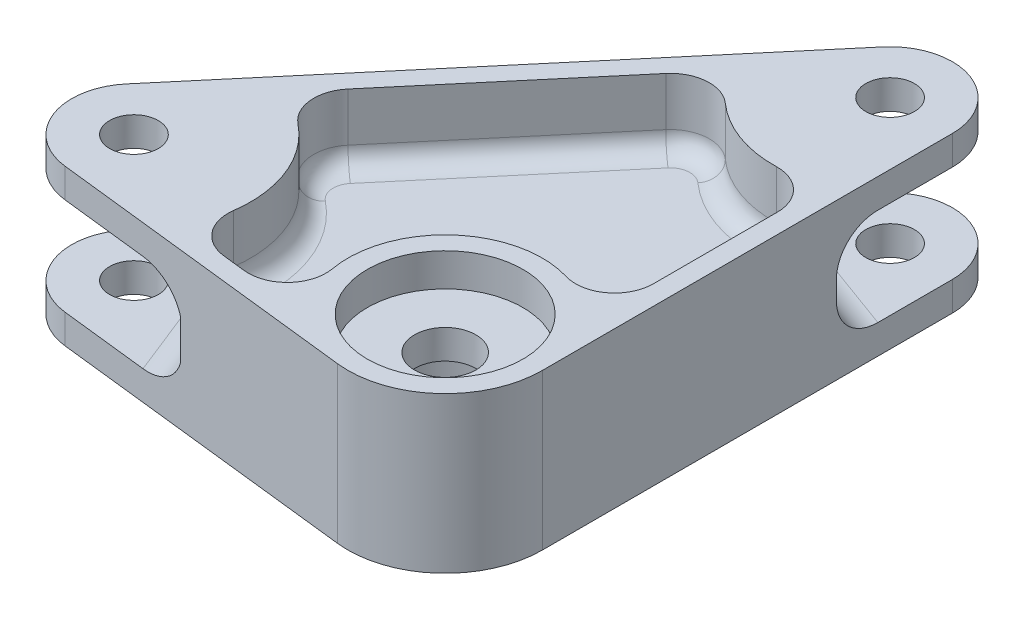
from build123d import *

# Parameters (mm, degrees)
BOSS_EXTRUDE2_DEPTH = 12.7
SKETCH3_R           = 12
CUT_EXTRUDE1_DEPTH  = 15.24
SKETCH5_R           = 3.96875
CUT_EXTRUDE3_DEPTH  = 26.4
SKETCH4_R           = 5
CUT_EXTRUDE2_DEPTH  = 26.4
CUT_EXTRUDE4_DEPTH  = 11.1125
CUT_EXTRUDE5_DEPTH  = 11.1125
SKETCH10_R          = 12.7
CUT_EXTRUDE6_DEPTH  = 5.3975
CUT_EXTRUDE7_REACH  = 29.328
SKETCH12_W          = 38.1
SKETCH12_H          = 15.875
CUT_EXTRUDE8_REACH  = 31.596
SKETCH15_W          = 38.1
SKETCH15_H          = 15.875
FILLET1_R           = 3.175
FILLET2_R           = 3.175
FILLET3_R           = 6.35
CHAMFER1_SIZE       = 0.635


with BuildPart() as part:
    # Sketch2 → Boss-Extrude2 (new body, symmetric)
    with BuildSketch(Plane(origin=(0, 0, 0), x_dir=(1, 0, 0), z_dir=(0, 1, 0))):
        with BuildLine():
            Line((-58.565346794, 6.551716506), (-2.085197783, 73.494164894))
            ThreePointArc((-2.085197783, 73.494164894), (9.165477674, 76.485932244), (15.840147634, 66.947737915))
            Line((15.840147634, 66.947737915), (15.874997849, 0.008264886))
            ThreePointArc((15.874997849, 0.008264886), (10.578143579, -11.83716619), (-1.7859375, -15.77422113))
            Line((-1.7859375, -15.77422113), (-51.943, -10.095501523))
            ThreePointArc((-51.943, -10.095501523), (-60.240451667, -3.755459003), (-58.565346794, 6.551716506))
        make_face()
    extrude(amount=BOSS_EXTRUDE2_DEPTH, both=True)

    # Sketch3 → Cut-Extrude1 (cut)
    with BuildSketch(Plane.XZ.offset(12.7)):
        Circle(SKETCH3_R)
    extrude(amount=-CUT_EXTRUDE1_DEPTH, mode=Mode.SUBTRACT)

    # Sketch5 → Cut-Extrude3 (cut, through all)
    with BuildSketch(Plane(origin=(0, 12.7, 0), x_dir=(1, 0, 0), z_dir=(0, 1, 0))):
        with Locations((-50.8, 0)):
            Circle(SKETCH5_R)
        with Locations((5.680149011, 66.942448388)):
            Circle(SKETCH5_R)
    extrude(amount=-CUT_EXTRUDE3_DEPTH, mode=Mode.SUBTRACT)

    # Sketch4 → Cut-Extrude2 (cut, through all)
    with BuildSketch(Plane(origin=(0, 12.7, 0), x_dir=(1, 0, 0), z_dir=(0, 1, 0))):
        Circle(SKETCH4_R)
    extrude(amount=-CUT_EXTRUDE2_DEPTH, mode=Mode.SUBTRACT)

    # Sketch6 → Cut-Extrude4 (cut)
    with BuildSketch(Plane(origin=(0, 12.7, 0), x_dir=(1, 0, 0), z_dir=(0, 1, 0))):
        with BuildLine():
            Line((-39.764503985, 23.911604457), (-16.032698846, 52.039454127))
            ThreePointArc((-16.032698846, 52.039454127), (-11.636571539, 54.278149682), (-6.964480572, 52.69408558))
            ThreePointArc((-6.964480572, 52.69408558), (-0.854842234, 49.048416159), (6.166313709, 47.898652971))
            ThreePointArc((6.166313709, 47.898652971), (10.759647518, 46.098936994), (12.678367748, 41.55402712))
            Line((12.678367748, 41.55402712), (12.688909771, 21.305156508))
            ThreePointArc((12.688909771, 21.305156508), (10.136411612, 16.212500271), (4.527793308, 15.215607538))
            ThreePointArc((4.527793308, 15.215607538), (-10.578143579, 11.83716619), (-15.626938173, -2.7954299))
            ThreePointArc((-15.626938173, -2.7954299), (-17.245628646, -8.257136186), (-22.592088443, -10.223290312))
            Line((-22.592088443, -10.223290312), (-26.354947036, -9.797264189))
            ThreePointArc((-26.354947036, -9.797264189), (-30.656406746, -7.381661273), (-31.930429027, -2.615681803))
            ThreePointArc((-31.930429027, -2.615681803), (-33.099153125, 7.041485631), (-38.883371679, 14.862586231))
            ThreePointArc((-38.883371679, 14.862586231), (-41.231270715, 19.201372144), (-39.764503985, 23.911604457))
        make_face()
    extrude(amount=-CUT_EXTRUDE4_DEPTH, mode=Mode.SUBTRACT)

    # Sketch8 → Cut-Extrude5 (cut)
    with BuildSketch(Plane.XZ.offset(12.7)):
        with BuildLine():
            Line((-26.354947036, 9.797264189), (-22.592088443, 10.223290312))
            ThreePointArc((-22.592088443, 10.223290312), (-17.245628646, 8.257136186), (-15.626938173, 2.7954299))
            ThreePointArc((-15.626938173, 2.7954299), (-10.578143579, -11.83716619), (4.527793308, -15.215607538))
            ThreePointArc((4.527793308, -15.215607538), (10.136411612, -16.212500271), (12.688909771, -21.305156508))
            Line((12.688909771, -21.305156508), (12.678367748, -41.55402712))
            ThreePointArc((12.678367748, -41.55402712), (10.759647518, -46.098936994), (6.166313709, -47.898652971))
            ThreePointArc((6.166313709, -47.898652971), (-0.854842234, -49.048416159), (-6.964480572, -52.69408558))
            ThreePointArc((-6.964480572, -52.69408558), (-11.636571539, -54.278149682), (-16.032698846, -52.039454127))
            Line((-16.032698846, -52.039454127), (-39.764503985, -23.911604457))
            ThreePointArc((-39.764503985, -23.911604457), (-41.231270715, -19.201372144), (-38.883371679, -14.862586231))
            ThreePointArc((-38.883371679, -14.862586231), (-33.099153125, -7.041485631), (-31.930429027, 2.615681803))
            ThreePointArc((-31.930429027, 2.615681803), (-30.656406746, 7.381661273), (-26.354947036, 9.797264189))
        make_face()
    extrude(amount=-CUT_EXTRUDE5_DEPTH, mode=Mode.SUBTRACT)

    # Sketch10 → Cut-Extrude6 (cut)
    with BuildSketch(Plane(origin=(0, 12.7, 0), x_dir=(1, 0, 0), z_dir=(0, 1, 0))):
        Circle(SKETCH10_R)
    extrude(amount=-CUT_EXTRUDE6_DEPTH, mode=Mode.SUBTRACT)

    # Sketch12 → Cut-Extrude7 (cut, up to next)
    with BuildSketch(Plane(origin=(17.337923239, 0, -47.474487057), x_dir=(0.939319277, 0, 0.34304416), z_dir=(-0.34304416, 0, 0.939319277)), mode=Mode.PRIVATE) as cut_extrude7_sk1:
        with Locations((-17.6287425, 0)):
            Rectangle(SKETCH12_W, SKETCH12_H)
    cut_extrude7_tool1 = extrude(cut_extrude7_sk1.sketch, amount=-CUT_EXTRUDE7_REACH, mode=Mode.PRIVATE) & part.part
    add(cut_extrude7_tool1.solids().sort_by_distance((0.778906, 0, -53.521924))[0], mode=Mode.SUBTRACT)

    # Sketch15 → Cut-Extrude8 (cut, up to next)
    with BuildSketch(Plane(origin=(-30.583679643, 0, 12.166341096), x_dir=(0.369631792, 0, 0.929178314), z_dir=(-0.929178314, 0, 0.369631792)), mode=Mode.PRIVATE) as cut_extrude8_sk1:
        with Locations((-18.777295017, 0)):
            Rectangle(SKETCH15_W, SKETCH15_H)
    cut_extrude8_tool1 = extrude(cut_extrude8_sk1.sketch, amount=CUT_EXTRUDE8_REACH, mode=Mode.PRIVATE) & part.part
    add(cut_extrude8_tool1.solids().sort_by_distance((-37.524365, 0, -5.281114))[0], mode=Mode.SUBTRACT)

    # Fillet1
    fillet1_edges = [part.edges().sort_by_distance(p)[0] for p in [
        (-30.656406746, 1.5875, 7.381661273),
        (-33.099153125, 1.5875, -7.041485631),
        (-41.231270715, 1.5875, -19.201372144),
        (-27.898601415, 1.5875, -37.975529292),
        (-11.636571539, 1.5875, -54.278149682),
        (-0.854842234, 1.5875, -49.048416159),
        (10.759647518, 1.5875, -46.098936994),
        (12.68363876, 1.5875, -31.429591814),
        (10.136411612, 1.5875, -16.212500271),
        (-10.578143579, 1.5875, -11.83716619),
        (-17.245628646, 1.5875, 8.257136186),
        (-24.473517739, 1.5875, 10.01027725),
    ]]
    fillet(fillet1_edges, radius=FILLET1_R)

    # Fillet2
    fillet2_edges = [part.edges().sort_by_distance(p)[0] for p in [
        (-17.245628646, -1.5875, 8.257136186),
        (-10.578143579, -1.5875, -11.83716619),
        (10.136411612, -1.5875, -16.212500271),
        (12.68363876, -1.5875, -31.429591814),
        (10.759647518, -1.5875, -46.098936994),
        (-0.854842234, -1.5875, -49.048416159),
        (-11.636571539, -1.5875, -54.278149682),
        (-27.898601415, -1.5875, -37.975529292),
        (-41.231270715, -1.5875, -19.201372144),
        (-33.099153125, -1.5875, -7.041485631),
        (-30.656406746, -1.5875, 7.381661273),
        (-24.473517739, -1.5875, 10.01027725),
    ]]
    fillet(fillet2_edges, radius=FILLET2_R)

    # Fillet3
    fillet3_edges = [part.edges().sort_by_distance(p)[0] for p in [
        (0.778905577, 7.9375, -53.521924216),
        (0.778905577, -7.9375, -53.521924216),
        (-37.524364844, 7.9375, -5.281114224),
        (-37.524364844, -7.9375, -5.281114224),
    ]]
    fillet(fillet3_edges, radius=FILLET3_R)

    # Chamfer1
    chamfer1_edges = [part.edges().sort_by_distance(p)[0] for p in [
        (-12, -12.7, 0),
    ]]
    chamfer(chamfer1_edges, length=CHAMFER1_SIZE)


solid = part.part
